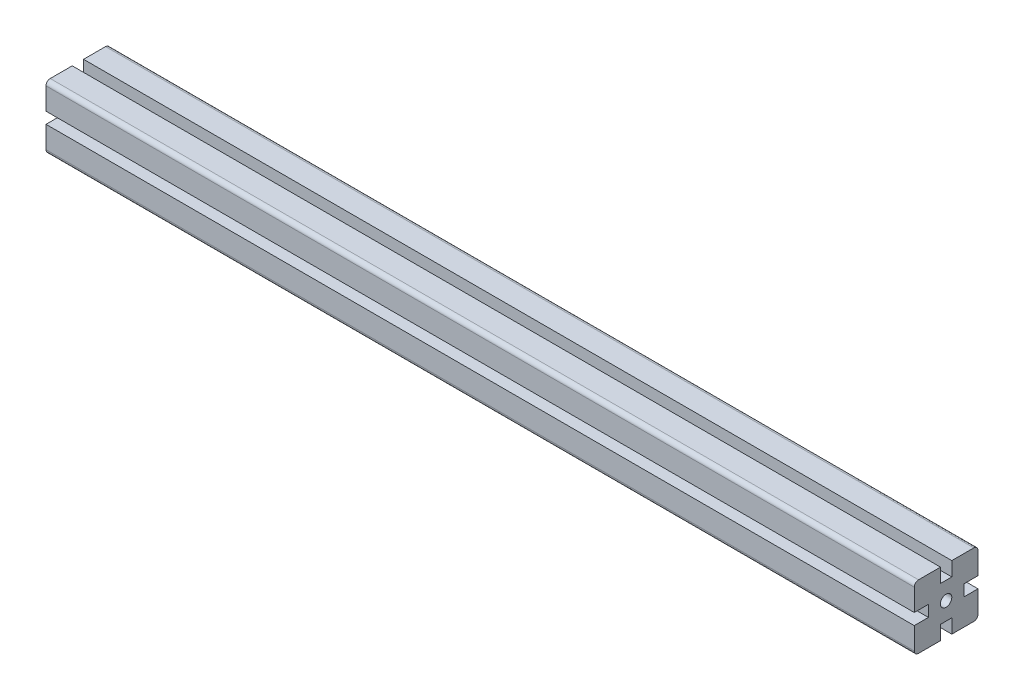
from build123d import *

# Parameters (mm, degrees)
ESQUISSE1_R        = 4
BOSS_EXTRU_1_DEPTH = 613
CONG_1_R           = 3


with BuildPart() as part:
    # Esquisse1 → Boss.-Extru.1 (new body)
    with BuildSketch(Plane(origin=(1000, 0, 0), x_dir=(0, 0, -1), z_dir=(1, 0, 0))):
        Polygon((22.5, -4), (12.5, -4), (12.5, 4), (22.5, 4), (22.5, 22.5), (4, 22.5), (4, 12.5), (-4, 12.5), (-4, 22.5), (-22.5, 22.5), (-22.5, 4), (-12.5, 4), (-12.5, -4), (-22.5, -4), (-22.5, -22.5), (-4, -22.5), (-4, -12.5), (4, -12.5), (4, -22.5), (22.5, -22.5), align=None)
        Circle(ESQUISSE1_R, mode=Mode.SUBTRACT)
    extrude(amount=-BOSS_EXTRU_1_DEPTH)

    # Congé1
    cong_1_edges = [part.edges().sort_by_distance(p)[0] for p in [
        (693.5, -22.5, -22.5),
        (693.5, -22.5, 22.5),
        (693.5, 22.5, 22.5),
        (693.5, 22.5, -22.5),
    ]]
    fillet(cong_1_edges, radius=CONG_1_R)


solid = part.part
